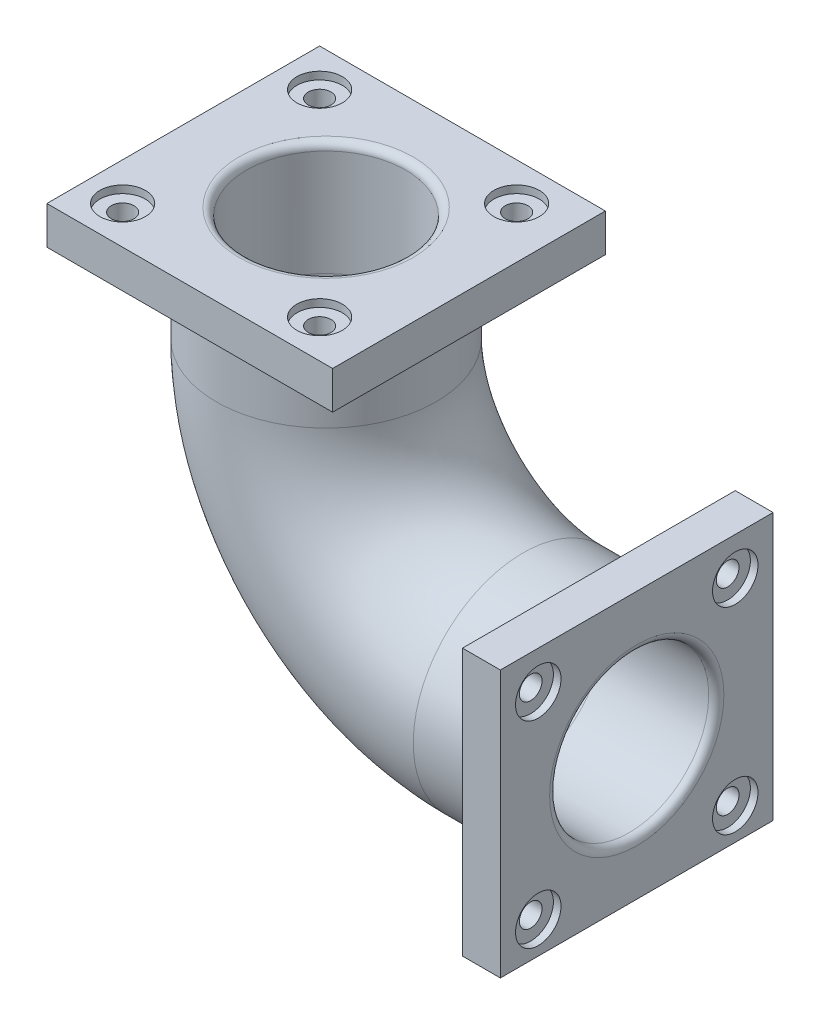
from build123d import *

# Parameters (mm, degrees)
SKETCH9_R           = 145
SKETCH9_R_2         = 105
SKETCH10_W          = 360
SKETCH10_H          = 352.085339176
BOSS_EXTRUDE1_DEPTH = 50
SKETCH12_R          = 15
SKETCH12_R_2        = 105
CUT_EXTRUDE3_DEPTH  = 50
SKETCH12_3_R        = 30
CUT_EXTRUDE4_DEPTH  = 10
SKETCH19_W          = 377.161076004
SKETCH19_H          = 360
BOSS_EXTRUDE2_DEPTH = 50
SKETCH20_R          = 105
SKETCH20_R_2        = 15
CUT_EXTRUDE5_DEPTH  = 50
SKETCH20_3_R        = 30
SKETCH20_3_R_2      = 15
CUT_EXTRUDE6_DEPTH  = 10
FILLET1_R           = 10


with BuildPart() as part:
    # Sweep-Thin1: sweep along a path in Sketch1
    with BuildLine(Plane.XY) as sweep_thin1_path:
        Line((-260, 100), (-260, 0))
        ThreePointArc((-260, 0), (-183.847763109, -183.847763109), (0, -260))
        Line((0, -260), (100, -260))
    # Sketch9 → Sweep-Thin1 (sweep)
    with BuildSketch(Plane(origin=(100, 0, 0), x_dir=(0, 0, -1), z_dir=(1, 0, 0))):
        with Locations((0, -260)):
            Circle(SKETCH9_R)
        with Locations((0, -260)):
            Circle(SKETCH9_R_2, mode=Mode.SUBTRACT)
    sweep(path=sweep_thin1_path.line)

    # Sketch10 → Boss-Extrude1 (add)
    with BuildSketch(Plane(origin=(100, 0, 0), x_dir=(0, 0, -1), z_dir=(1, 0, 0))):
        with Locations((0, -260)):
            Rectangle(SKETCH10_W, SKETCH10_H)
    extrude(amount=BOSS_EXTRUDE1_DEPTH)

    # Sketch12 → Cut-Extrude3 (cut)
    with BuildSketch(Plane(origin=(150, 0, 0), x_dir=(0, 0, -1), z_dir=(1, 0, 0))):
        with Locations((-130, -133.957330412)):
            Circle(SKETCH12_R)
        with Locations((130, -133.957330412)):
            Circle(SKETCH12_R)
        with Locations((130, -393.957330412)):
            Circle(SKETCH12_R)
        with Locations((-130, -393.957330412)):
            Circle(SKETCH12_R)
        with Locations((0, -260)):
            Circle(SKETCH12_R_2)
    extrude(amount=-CUT_EXTRUDE3_DEPTH, mode=Mode.SUBTRACT)

    # Sketch12_3 → Cut-Extrude4 (cut)
    with BuildSketch(Plane(origin=(150, 0, 0), x_dir=(0, 0, -1), z_dir=(1, 0, 0))):
        with Locations((-130, -133.957330412)):
            Circle(SKETCH12_3_R)
        with Locations((130, -133.957330412)):
            Circle(SKETCH12_3_R)
        with Locations((130, -393.957330412)):
            Circle(SKETCH12_3_R)
        with Locations((-130, -393.957330412)):
            Circle(SKETCH12_3_R)
    extrude(amount=-CUT_EXTRUDE4_DEPTH, mode=Mode.SUBTRACT)

    # Sketch19 → Boss-Extrude2 (add)
    with BuildSketch(Plane(origin=(0, 100, 0), x_dir=(1, 0, 0), z_dir=(0, 1, 0))):
        with Locations((-260, 0)):
            Rectangle(SKETCH19_W, SKETCH19_H)
    extrude(amount=BOSS_EXTRUDE2_DEPTH)

    # Sketch20 → Cut-Extrude5 (cut)
    with BuildSketch(Plane(origin=(0, 150, 0), x_dir=(1, 0, 0), z_dir=(0, 1, 0))):
        with Locations(Location((-260, 0, 0), (0, 0, 180))):
            Circle(SKETCH20_R)
        with Locations(Location((-398.580538002, -130, 0), (0, 0, 270))):
            Circle(SKETCH20_R_2)
        with Locations(Location((-398.580538002, 130, 0), (0, 0, 270))):
            Circle(SKETCH20_R_2)
        with Locations(Location((-138.580538002, 130, 0), (0, 0, 270))):
            Circle(SKETCH20_R_2)
        with Locations(Location((-138.580538002, -130, 0), (0, 0, 270))):
            Circle(SKETCH20_R_2)
    extrude(amount=-CUT_EXTRUDE5_DEPTH, mode=Mode.SUBTRACT)

    # Sketch20_3 → Cut-Extrude6 (cut)
    with BuildSketch(Plane(origin=(0, 150, 0), x_dir=(1, 0, 0), z_dir=(0, 1, 0))):
        with Locations(Location((-138.580538002, -130, 0), (0, 0, 270))):
            Circle(SKETCH20_3_R)
        with Locations(Location((-138.580538002, -130, 0), (0, 0, 270))):
            Circle(SKETCH20_3_R_2, mode=Mode.SUBTRACT)
        with Locations(Location((-138.580538002, 130, 0), (0, 0, 270))):
            Circle(SKETCH20_3_R)
        with Locations(Location((-138.580538002, 130, 0), (0, 0, 270))):
            Circle(SKETCH20_3_R_2, mode=Mode.SUBTRACT)
        with Locations(Location((-398.580538002, 130, 0), (0, 0, 270))):
            Circle(SKETCH20_3_R)
        with Locations(Location((-398.580538002, 130, 0), (0, 0, 270))):
            Circle(SKETCH20_3_R_2, mode=Mode.SUBTRACT)
        with Locations(Location((-398.580538002, -130, 0), (0, 0, 270))):
            Circle(SKETCH20_3_R)
        with Locations(Location((-398.580538002, -130, 0), (0, 0, 270))):
            Circle(SKETCH20_3_R_2, mode=Mode.SUBTRACT)
    extrude(amount=-CUT_EXTRUDE6_DEPTH, mode=Mode.SUBTRACT)

    # Fillet1
    fillet1_edges = [part.edges().sort_by_distance(p)[0] for p in [
        (-155, 150, 0),
        (150, -260, 105),
    ]]
    fillet(fillet1_edges, radius=FILLET1_R)


solid = part.part
